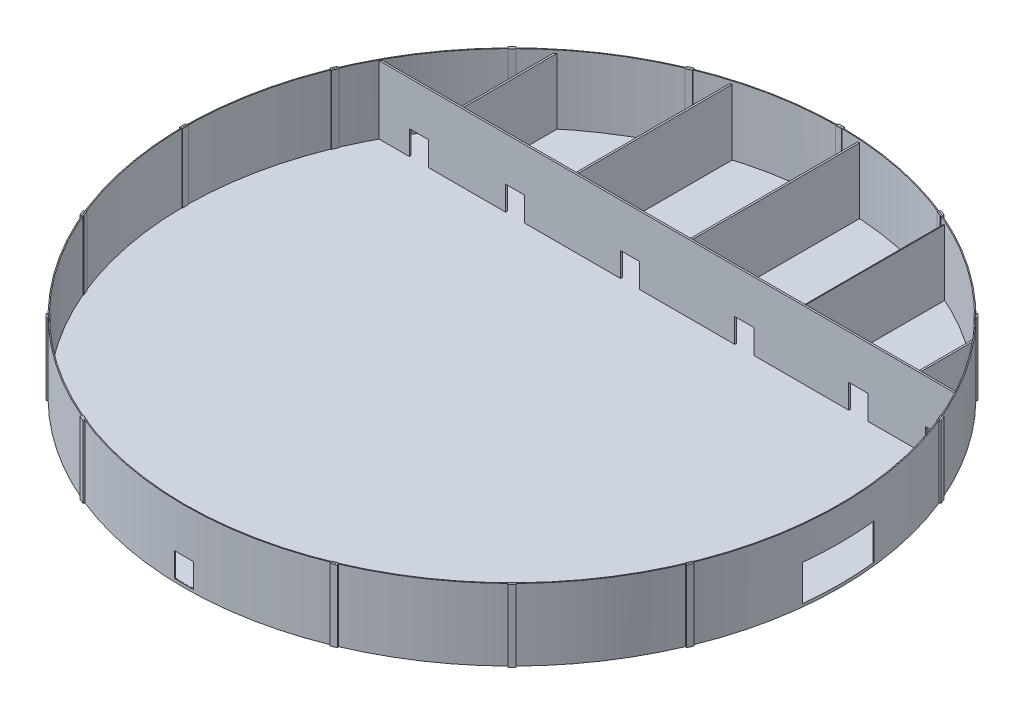
from build123d import *

# Parameters (mm, degrees)
SKETCH1_R             = 27500
BOSS_EXTRUDE2_DEPTH   = 6000
SKETCH2_R             = 27425
CUT_EXTRUDE1_DEPTH    = 5750
SKETCH5_W             = 1600
SKETCH5_H             = 2032
CUT_EXTRUDE4_DEPTH    = 1263.5
BOSS_EXTRUDE5_DEPTH   = 5750
BOSS_EXTRUDE5_2_DEPTH = 5750
BOSS_EXTRUDE5_3_DEPTH = 5750
BOSS_EXTRUDE5_4_DEPTH = 5750
BOSS_EXTRUDE5_5_DEPTH = 5750
SKETCH9_W             = 6000
SKETCH9_H             = 3000
CUT_EXTRUDE5_DEPTH    = 5750
BOSS_EXTRUDE9_DEPTH   = 5700
SKETCH15_W            = 1600
SKETCH15_H            = 2030
CUT_EXTRUDE13_DEPTH   = 500
SKETCH14_W            = 1600
SKETCH14_H            = 2030
CUT_EXTRUDE14_DEPTH   = 500
SKETCH21_W            = 500
SKETCH21_H            = 5997.704847116
BOSS_EXTRUDE10_DEPTH  = 125
CIRPATTERN1_COUNT     = 16


with BuildPart() as part:
    # Sketch1 → Boss-Extrude2 (new body)
    with BuildSketch(Plane(origin=(0, 0, 0), x_dir=(1, 0, 0), z_dir=(0, 1, 0))):
        Circle(SKETCH1_R)
    extrude(amount=BOSS_EXTRUDE2_DEPTH)

    # Sketch2 → Cut-Extrude1 (cut)
    with BuildSketch(Plane(origin=(0, 6000, 0), x_dir=(1, 0, 0), z_dir=(0, 1, 0))):
        Circle(SKETCH2_R)
    extrude(amount=-CUT_EXTRUDE1_DEPTH, mode=Mode.SUBTRACT)

    # Sketch5 → Cut-Extrude4 (cut, symmetric)
    with BuildSketch(Plane.XY.offset(27500)):
        with Locations((-8.803684709, 1268)):
            Rectangle(SKETCH5_W, SKETCH5_H)
    extrude(amount=CUT_EXTRUDE4_DEPTH, both=True, mode=Mode.SUBTRACT)

    # Sketch9 → Cut-Extrude5 (cut)
    with BuildSketch(Plane(origin=(27500, 0, 0), x_dir=(0, 0, -1), z_dir=(1, 0, 0))):
        with Locations((0, 1750)):
            Rectangle(SKETCH9_W, SKETCH9_H)
    extrude(amount=-CUT_EXTRUDE5_DEPTH, mode=Mode.SUBTRACT)

    # Sketch21 → Boss-Extrude10 (add, symmetric)
    with BuildSketch(Plane.XY.offset(-27500)):
        with Locations((0, 2998.852423558)):
            Rectangle(SKETCH21_W, SKETCH21_H)
    boss_extrude10 = extrude(amount=BOSS_EXTRUDE10_DEPTH, both=True)

    # CirPattern1: Boss-Extrude10 ×16 about axis, 2 skipped
    cirpattern1_axis = Axis((0, 0, 0), (0, -1, 0))
    add([boss_extrude10.rotate(cirpattern1_axis, i * 360 / CIRPATTERN1_COUNT) for i in range(1, CIRPATTERN1_COUNT) if i not in (4, 8)])


with BuildPart() as body_2:
    # Sketch8 → Boss-Extrude5 (new body)
    with BuildSketch(Plane(origin=(0, 0, 0), x_dir=(1, 0, 0), z_dir=(0, 1, 0))):
        Polygon((-7969.027698128, 26241.669583822), (-7969.027698128, 13140), (-7817.027698128, 13150), (-7817.027698128, 26287.348724561), align=None)
    extrude(amount=BOSS_EXTRUDE5_DEPTH)


with BuildPart() as body_3:
    # Sketch8 → Boss-Extrude5 2 (new body)
    with BuildSketch(Plane(origin=(0, 0, 0), x_dir=(1, 0, 0), z_dir=(0, 1, 0))):
        Polygon((-17559.027698128, 21066.826322357), (-17407.027698128, 21192.593322116), (-17407.027698128, 13140), (-17559.027698128, 13140), align=None)
    extrude(amount=BOSS_EXTRUDE5_2_DEPTH)


with BuildPart() as body_4:
    # Sketch8 → Boss-Extrude5 3 (new body)
    with BuildSketch(Plane(origin=(0, 0, 0), x_dir=(1, 0, 0), z_dir=(0, 1, 0))):
        Polygon((11210.972301872, 25028.877822361), (11210.972301872, 13140), (11279.496411372, 13140), (11279.496411372, 24997.924225866), align=None)
    extrude(amount=BOSS_EXTRUDE5_3_DEPTH)


with BuildPart() as body_5:
    # Sketch8 → Boss-Extrude5 4 (new body)
    with BuildSketch(Plane(origin=(0, 0, 0), x_dir=(1, 0, 0), z_dir=(0, 1, 0))):
        Polygon((20800.972301872, 17823.212803973), (20800.972301872, 13140), (20952.972301872, 13140), (20952.972301872, 17694.733021919), align=None)
    extrude(amount=BOSS_EXTRUDE5_4_DEPTH)


with BuildPart() as body_6:
    # Sketch8 → Boss-Extrude5 5 (new body)
    with BuildSketch(Plane(origin=(0, 0, 0), x_dir=(1, 0, 0), z_dir=(0, 1, 0))):
        Polygon((1620.972301872, 27377.053782257), (1620.972301872, 13150), (1772.972301872, 13140), (1772.972301872, 27367.630409241), align=None)
    extrude(amount=BOSS_EXTRUDE5_5_DEPTH)


with BuildPart() as body_7:
    # Sketch6 → Boss-Extrude9 (new body)
    with BuildSketch(Plane(origin=(0, 250, 0), x_dir=(1, 0, 0), z_dir=(0, 1, 0))):
        Polygon((23976.203154884, 13150), (24148.097751169, 13000), (-24148.097751169, 13000), (-23976.203154884, 13150), align=None)
    extrude(amount=BOSS_EXTRUDE9_DEPTH)

    # Sketch15 → Cut-Extrude13 (cut, symmetric)
    with BuildSketch(Plane.XY.offset(-13150)):
        with Locations((-3095.739213372, 1265)):
            Rectangle(SKETCH15_W, SKETCH15_H)
        with Locations((16029.620717869, 1265)):
            Rectangle(SKETCH15_W, SKETCH15_H)
        with Locations((6471.802297599, 1265)):
            Rectangle(SKETCH15_W, SKETCH15_H)
        with Locations((22460.055479199, 1265)):
            Rectangle(SKETCH15_W, SKETCH15_H)
        with Locations((-20806.568426173, 1265)):
            Rectangle(SKETCH15_W, SKETCH15_H)
    extrude(amount=CUT_EXTRUDE13_DEPTH, both=True, mode=Mode.SUBTRACT)

    # Sketch14 → Cut-Extrude14 (cut, symmetric)
    with BuildSketch(Plane.XY.offset(-13150)):
        with Locations((-12734.625099051, 1265)):
            Rectangle(SKETCH14_W, SKETCH14_H)
    extrude(amount=CUT_EXTRUDE14_DEPTH, both=True, mode=Mode.SUBTRACT)


solid = Compound([part.part, body_2.part, body_3.part, body_4.part, body_5.part, body_6.part, body_7.part])
